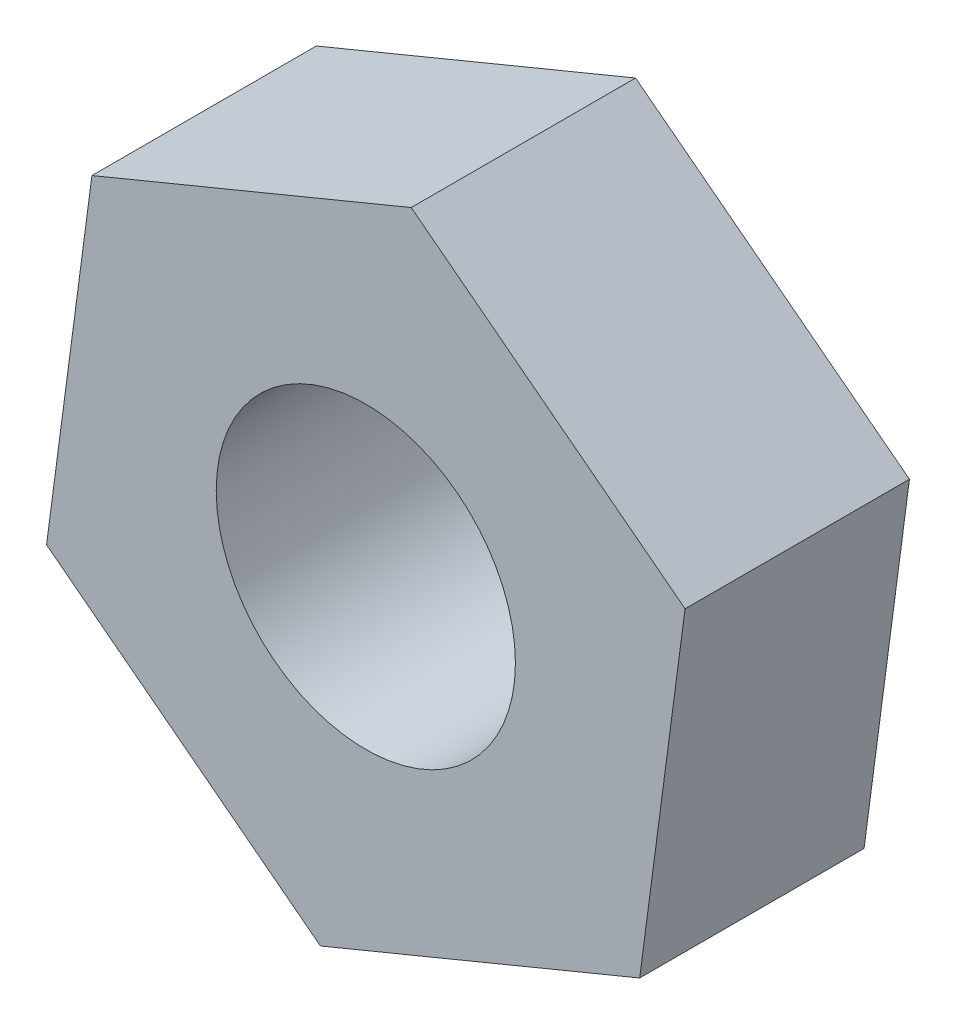
from build123d import *

# Parameters (mm, degrees)
SKETCH_1_R      = 1
EXTRUDE_1_DEPTH = 1.5


with BuildPart() as part:
    # 草图1 → 凸台-拉伸1 (new body)
    with BuildSketch(Plane.XY):
        Polygon((1.830949622, -1.407464676), (2.134374975, 0.881916548), (0.303425353, 2.289381224), (-1.830949622, 1.407464676), (-2.134374975, -0.881916548), (-0.303425353, -2.289381224), align=None)
        Circle(SKETCH_1_R, mode=Mode.SUBTRACT)
    extrude(amount=EXTRUDE_1_DEPTH)


solid = part.part
